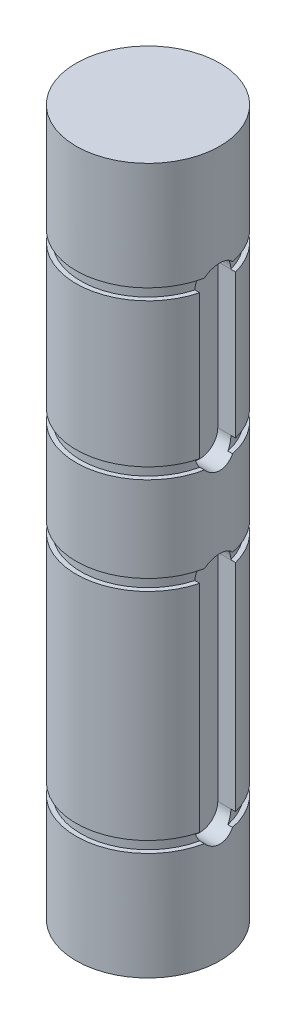
from build123d import *

# Parameters (mm, degrees)
SKETCH1_R           = 6.35
BOSS_EXTRUDE1_DEPTH = 62.3062
SKETCH2_W           = 25.005940549
SKETCH2_H           = 0.9906
SKETCH3_W           = 23.546175461
SKETCH3_H           = 0.9906
SKETCH4_W           = 18.658380353
SKETCH4_H           = 0.9906
SKETCH5_W           = 21.890491914
SKETCH5_H           = 0.9906
CUT_EXTRUDE1_DEPTH  = 1.778
CUT_EXTRUDE2_DEPTH  = 1.778


with BuildPart() as part:
    # Sketch1 → Boss-Extrude1 (new body)
    with BuildSketch(Plane(origin=(0, 0, 0), x_dir=(1, 0, 0), z_dir=(0, 1, 0))):
        Circle(SKETCH1_R)
    extrude(amount=BOSS_EXTRUDE1_DEPTH)

    # Sketch2 → Cut-Revolve1 (revolve, cut)
    with BuildSketch(Plane(origin=(0, 0, 0), x_dir=(0, 0, -1), z_dir=(1, 0, 0))):
        with Locations((-18.446570275, 52.2859)):
            Rectangle(SKETCH2_W, SKETCH2_H)
    revolve(axis=Axis((0, 57.347973558, 0), (0, -1, 0)), mode=Mode.SUBTRACT)

    # Sketch3 → Cut-Revolve2 (revolve, cut)
    with BuildSketch(Plane(origin=(0, 0, 0), x_dir=(0, 0, -1), z_dir=(1, 0, 0))):
        with Locations((-17.71668773, 38.5953)):
            Rectangle(SKETCH3_W, SKETCH3_H)
    revolve(axis=Axis((0, 44.893049612, 0), (0, -1, 0)), mode=Mode.SUBTRACT)

    # Sketch4 → Cut-Revolve3 (revolve, cut)
    with BuildSketch(Plane(origin=(0, 0, 0), x_dir=(0, 0, -1), z_dir=(1, 0, 0))):
        with Locations((-15.272790177, 30.0609)):
            Rectangle(SKETCH4_W, SKETCH4_H)
    revolve(axis=Axis((0, 32.886405358, 0), (0, -1, 0)), mode=Mode.SUBTRACT)

    # Sketch5 → Cut-Revolve4 (revolve, cut)
    with BuildSketch(Plane(origin=(0, 0, 0), x_dir=(0, 0, -1), z_dir=(1, 0, 0))):
        with Locations((-16.888845957, 10.0203)):
            Rectangle(SKETCH5_W, SKETCH5_H)
    revolve(axis=Axis((0, 12.888921404, 0), (0, -1, 0)), mode=Mode.SUBTRACT)

    # Sketch6 → Cut-Extrude1 (cut)
    with BuildSketch(Plane(origin=(6.35, 0, 0), x_dir=(0, 0, -1), z_dir=(1, 0, 0))):
        with BuildLine():
            Line((1.5875, 51.7906), (1.5875, 39.0906))
            ThreePointArc((1.5875, 39.0906), (0, 37.5031), (-1.5875, 39.0906))
            Line((-1.5875, 39.0906), (-1.5875, 51.7906))
            ThreePointArc((-1.5875, 51.7906), (0, 53.3781), (1.5875, 51.7906))
        make_face()
    extrude(amount=-CUT_EXTRUDE1_DEPTH, mode=Mode.SUBTRACT)

    # Sketch7 → Cut-Extrude2 (cut)
    with BuildSketch(Plane(origin=(6.35, 0, 0), x_dir=(0, 0, -1), z_dir=(1, 0, 0))):
        with BuildLine():
            Line((1.5875, 29.5656), (1.5875, 10.5156))
            ThreePointArc((1.5875, 10.5156), (0, 8.9281), (-1.5875, 10.5156))
            Line((-1.5875, 10.5156), (-1.5875, 29.5656))
            ThreePointArc((-1.5875, 29.5656), (0, 31.1531), (1.5875, 29.5656))
        make_face()
    extrude(amount=-CUT_EXTRUDE2_DEPTH, mode=Mode.SUBTRACT)


solid = part.part
